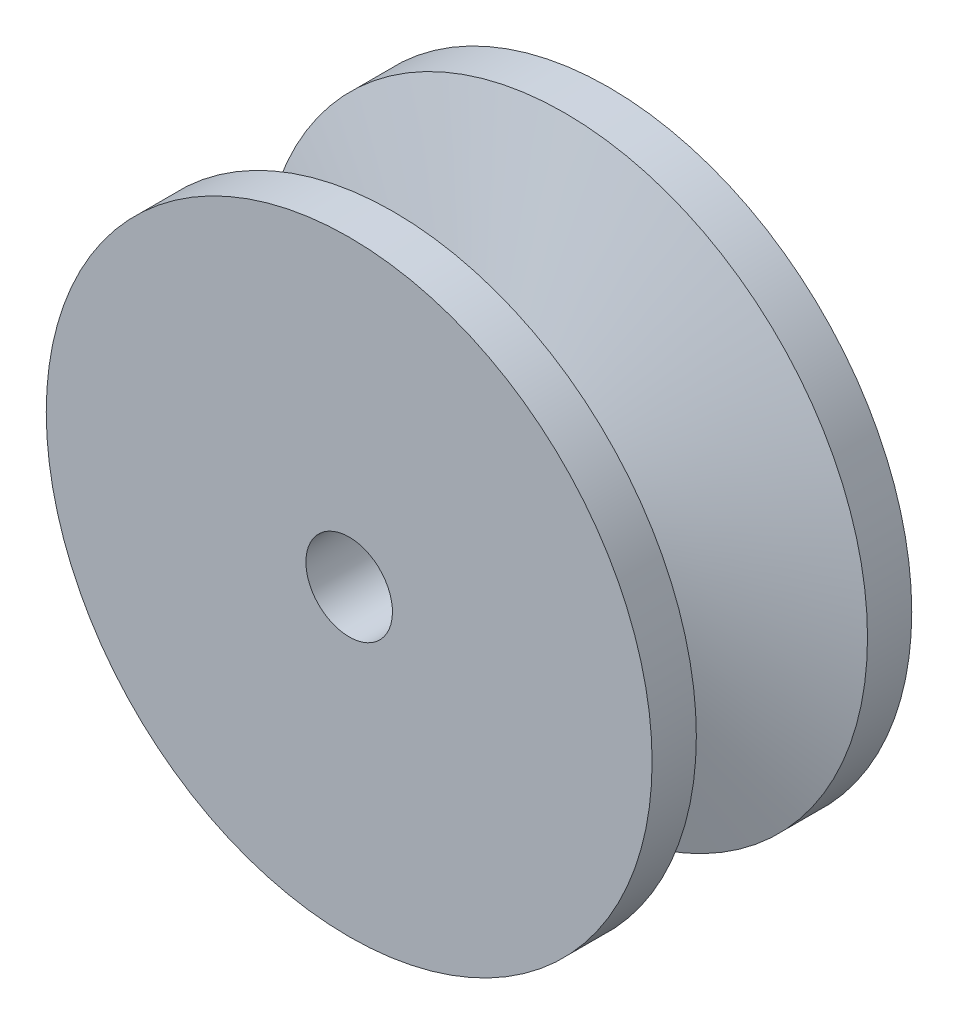
from build123d import *

# Parameters (mm, degrees)
SKETCH2_R          = 3.175
CUT_EXTRUDE1_DEPTH = 19.05


with BuildPart() as part:
    # Sketch1 → Revolve1 (revolve)
    with BuildSketch(Plane(origin=(0, 0, 0), x_dir=(0, 0, -1), z_dir=(1, 0, 0))):
        Polygon((6.279294914, 22.225), (9.525, 22.225), (9.525, 0), (-9.525, 0), (-9.525, 22.225), (-6.279294914, 22.225), (-2.474170852, 9.779), (2.474170852, 9.779), align=None)
    revolve(axis=Axis((0, 0, 9.525), (0, 0, -1)))

    # Sketch2 → Cut-Extrude1 (cut)
    with BuildSketch(Plane(origin=(0, 0, -9.525), x_dir=(-1, 0, 0), z_dir=(0, 0, -1))):
        Circle(SKETCH2_R)
    extrude(amount=-CUT_EXTRUDE1_DEPTH, mode=Mode.SUBTRACT)


solid = part.part
